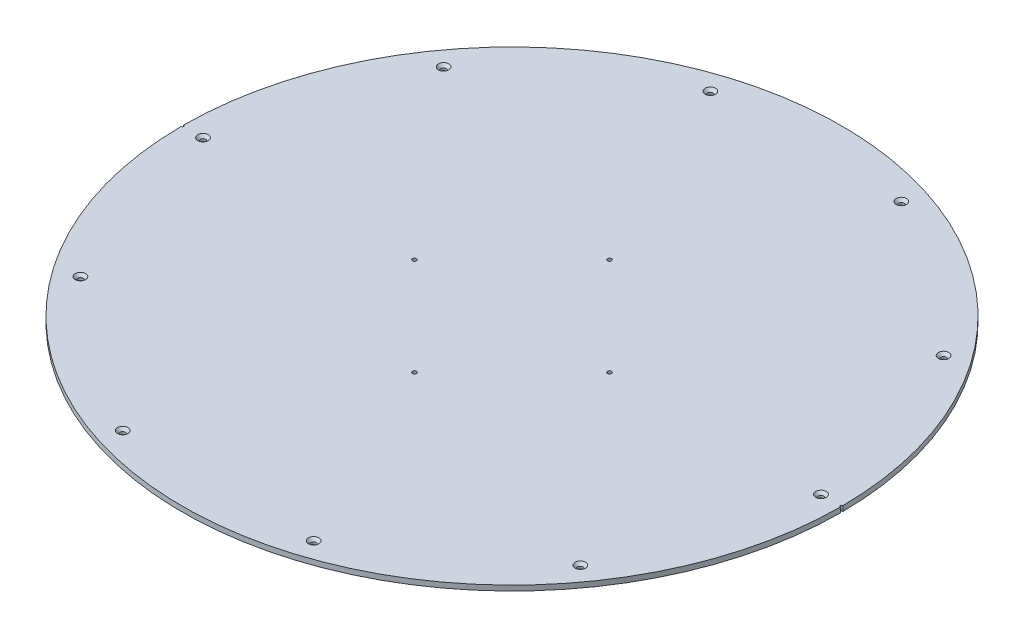
from build123d import *

# Parameters (mm, degrees)
SKETCH1_R                                     = 406.4
BOSS_EXTRUDE1_DEPTH                           = 6.35
CSK_FOR_1_4_FLAT_HEAD_MACHINE_SCREW1_AT_COUNT = 2
CSK_FOR_1_4_FLAT_HEAD_MACHINE_SCREW1_AT_PITCH = 235.470949714
CSK_FOR_1_4_FLAT_HEAD_MACHINE_SCREW1_2_COUNT  = 2
CSK_FOR_1_4_FLAT_HEAD_MACHINE_SCREW1_2_PITCH  = 447.892362247
CSK_FOR_1_4_FLAT_HEAD_MACHINE_SCREW1_3_COUNT  = 2
CSK_FOR_1_4_FLAT_HEAD_MACHINE_SCREW1_3_PITCH  = 616.470949714
CSK_FOR_1_4_FLAT_HEAD_MACHINE_SCREW1_4_COUNT  = 2
CSK_FOR_1_4_FLAT_HEAD_MACHINE_SCREW1_4_PITCH  = 724.705065417
CSK_FOR_1_4_FLAT_HEAD_MACHINE_SCREW1_5_COUNT  = 2
CSK_FOR_1_4_FLAT_HEAD_MACHINE_SCREW1_5_PITCH  = 762
CSK_FOR_1_4_FLAT_HEAD_MACHINE_SCREW1_6_COUNT  = 2
CSK_FOR_1_4_FLAT_HEAD_MACHINE_SCREW1_6_PITCH  = 724.705065417
CSK_FOR_1_4_FLAT_HEAD_MACHINE_SCREW1_7_COUNT  = 2
CSK_FOR_1_4_FLAT_HEAD_MACHINE_SCREW1_7_PITCH  = 616.470949714
CSK_FOR_1_4_FLAT_HEAD_MACHINE_SCREW1_8_COUNT  = 2
CSK_FOR_1_4_FLAT_HEAD_MACHINE_SCREW1_8_PITCH  = 447.892362247
CSK_FOR_1_4_FLAT_HEAD_MACHINE_SCREW1_9_COUNT  = 2
CSK_FOR_1_4_FLAT_HEAD_MACHINE_SCREW1_9_PITCH  = 235.470949714
F_10_0_1935_DIAMETER_HOLE1_D                  = 4.9149
F_1_8_0_125_DIAMETER_HOLE1_D                  = 3.175


with BuildPart() as part:
    # Sketch1 → Boss-Extrude1 (new body)
    with BuildSketch(Plane(origin=(0, 0, 0), x_dir=(1, 0, 0), z_dir=(0, 1, 0))):
        Circle(SKETCH1_R)
    extrude(amount=BOSS_EXTRUDE1_DEPTH)

    # Sketch6 → CSK for 1/4 Flat Head Machine Screw1 (revolve, cut)
    with BuildSketch(Plane(origin=(-117.735474857, 6.35, -362.352532708), x_dir=(0, 0, 1), z_dir=(1, 0, 0))):
        Polygon((0, 0), (0, 6.35), (3.3782, 6.35), (3.3782, 3.520932584), (6.4389, 0), align=None)
    csk_for_1_4_flat_head_machine_screw1 = revolve(axis=Axis((-117.735474857, 12.7, -362.352532708), (0, -1, 0)), mode=Mode.SUBTRACT)

    # CSK for 1/4 Flat Head Machine Screw1 at: CSK for 1/4 Flat Head Machine Screw1 ×2
    with Locations(*[(i * CSK_FOR_1_4_FLAT_HEAD_MACHINE_SCREW1_AT_PITCH, 0, 0) for i in range(1, CSK_FOR_1_4_FLAT_HEAD_MACHINE_SCREW1_AT_COUNT)]):
        add(csk_for_1_4_flat_head_machine_screw1, mode=Mode.SUBTRACT)

    # CSK for 1_4 Flat Head Machine Screw1 2: CSK for 1/4 Flat Head Machine Screw1 ×2
    with Locations(*[Vector(0.951056516, 0, 0.309016994) * (i * CSK_FOR_1_4_FLAT_HEAD_MACHINE_SCREW1_2_PITCH) for i in range(1, CSK_FOR_1_4_FLAT_HEAD_MACHINE_SCREW1_2_COUNT)]):
        add(csk_for_1_4_flat_head_machine_screw1, mode=Mode.SUBTRACT)

    # CSK for 1_4 Flat Head Machine Screw1 3: CSK for 1/4 Flat Head Machine Screw1 ×2
    with Locations(*[Vector(0.809016994, 0, 0.587785252) * (i * CSK_FOR_1_4_FLAT_HEAD_MACHINE_SCREW1_3_PITCH) for i in range(1, CSK_FOR_1_4_FLAT_HEAD_MACHINE_SCREW1_3_COUNT)]):
        add(csk_for_1_4_flat_head_machine_screw1, mode=Mode.SUBTRACT)

    # CSK for 1_4 Flat Head Machine Screw1 4: CSK for 1/4 Flat Head Machine Screw1 ×2
    with Locations(*[Vector(0.587785252, 0, 0.809016994) * (i * CSK_FOR_1_4_FLAT_HEAD_MACHINE_SCREW1_4_PITCH) for i in range(1, CSK_FOR_1_4_FLAT_HEAD_MACHINE_SCREW1_4_COUNT)]):
        add(csk_for_1_4_flat_head_machine_screw1, mode=Mode.SUBTRACT)

    # CSK for 1_4 Flat Head Machine Screw1 5: CSK for 1/4 Flat Head Machine Screw1 ×2
    with Locations(*[Vector(0.309016994, 0, 0.951056516) * (i * CSK_FOR_1_4_FLAT_HEAD_MACHINE_SCREW1_5_PITCH) for i in range(1, CSK_FOR_1_4_FLAT_HEAD_MACHINE_SCREW1_5_COUNT)]):
        add(csk_for_1_4_flat_head_machine_screw1, mode=Mode.SUBTRACT)

    # CSK for 1_4 Flat Head Machine Screw1 6: CSK for 1/4 Flat Head Machine Screw1 ×2
    with Locations(*[(0, 0, i * CSK_FOR_1_4_FLAT_HEAD_MACHINE_SCREW1_6_PITCH) for i in range(1, CSK_FOR_1_4_FLAT_HEAD_MACHINE_SCREW1_6_COUNT)]):
        add(csk_for_1_4_flat_head_machine_screw1, mode=Mode.SUBTRACT)

    # CSK for 1_4 Flat Head Machine Screw1 7: CSK for 1/4 Flat Head Machine Screw1 ×2
    with Locations(*[Vector(-0.309016994, 0, 0.951056516) * (i * CSK_FOR_1_4_FLAT_HEAD_MACHINE_SCREW1_7_PITCH) for i in range(1, CSK_FOR_1_4_FLAT_HEAD_MACHINE_SCREW1_7_COUNT)]):
        add(csk_for_1_4_flat_head_machine_screw1, mode=Mode.SUBTRACT)

    # CSK for 1_4 Flat Head Machine Screw1 8: CSK for 1/4 Flat Head Machine Screw1 ×2
    with Locations(*[Vector(-0.587785252, 0, 0.809016994) * (i * CSK_FOR_1_4_FLAT_HEAD_MACHINE_SCREW1_8_PITCH) for i in range(1, CSK_FOR_1_4_FLAT_HEAD_MACHINE_SCREW1_8_COUNT)]):
        add(csk_for_1_4_flat_head_machine_screw1, mode=Mode.SUBTRACT)

    # CSK for 1_4 Flat Head Machine Screw1 9: CSK for 1/4 Flat Head Machine Screw1 ×2
    with Locations(*[Vector(-0.809016994, 0, 0.587785252) * (i * CSK_FOR_1_4_FLAT_HEAD_MACHINE_SCREW1_9_PITCH) for i in range(1, CSK_FOR_1_4_FLAT_HEAD_MACHINE_SCREW1_9_COUNT)]):
        add(csk_for_1_4_flat_head_machine_screw1, mode=Mode.SUBTRACT)

    # #10 (0.1935) Diameter Hole1 (through all)
    with Locations(Plane(origin=(0, 6.35, 0), x_dir=(1, 0, 0), z_dir=(0, 1, 0))):
        with Locations((0, -120.2563), (120.2563, 0), (0, 120.2563), (-120.2563, 0)):
            Hole(F_10_0_1935_DIAMETER_HOLE1_D / 2)

    # 1/8 (0.125) Diameter Hole1 (through all)
    with Locations(Plane(origin=(0, 6.35, 0), x_dir=(1, 0, 0), z_dir=(0, 1, 0))):
        with Locations((-406.4, 0), (406.4, 0)):
            Hole(F_1_8_0_125_DIAMETER_HOLE1_D / 2)


solid = part.part
